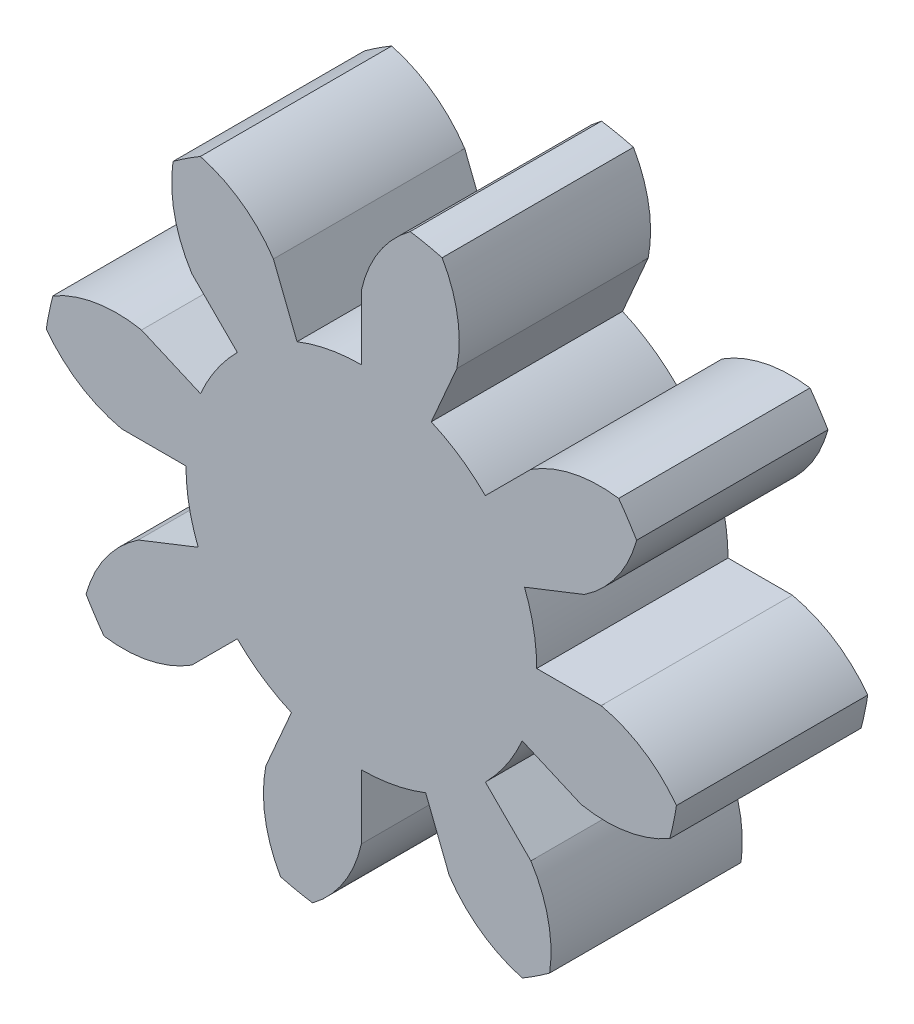
from build123d import *

# Parameters (mm, degrees)
BOSS_EXTRU_1_DEPTH           = 3
R_P_TITION_CIRCULAIRE2_COUNT = 8
ESQUISSE5_R                  = 2.75
BOSS_EXTRU_2_DEPTH           = 3


with BuildPart() as part:
    # Esquisse4 → Boss.-Extru.1 (new body)
    with BuildSketch(Plane.XY):
        with BuildLine():
            Line((0, 3.758770483), (0, 2.75))
            ThreePointArc((0, 2.75), (0.559711277, 2.692438168), (1.095991276, 2.52216239))
            Line((1.095991276, 2.52216239), (1.498028967, 3.447356198))
            ThreePointArc((1.498028967, 3.447356198), (1.508290586, 4.162952408), (1.26714265, 4.836770566))
            ThreePointArc((1.26714265, 4.836770566), (1.017656867, 4.895342123), (0.765497749, 4.941053855))
            ThreePointArc((0.765497749, 4.941053855), (0.275783903, 4.419169208), (0, 3.758770483))
        make_face()
    extrude(amount=BOSS_EXTRU_1_DEPTH)


with BuildPart() as r_p_tition_circulaire2_1:
    # Répétition circulaire2: pattern copy
    add(part.part.rotate(Axis((0, 0, 0), (0, 0, 1)), 1 * 360 / R_P_TITION_CIRCULAIRE2_COUNT))


with BuildPart() as r_p_tition_circulaire2_2:
    # Répétition circulaire2: pattern copy
    add(part.part.rotate(Axis((0, 0, 0), (0, 0, 1)), 2 * 360 / R_P_TITION_CIRCULAIRE2_COUNT))


with BuildPart() as r_p_tition_circulaire2_3:
    # Répétition circulaire2: pattern copy
    add(part.part.rotate(Axis((0, 0, 0), (0, 0, 1)), 3 * 360 / R_P_TITION_CIRCULAIRE2_COUNT))


with BuildPart() as r_p_tition_circulaire2_4:
    # Répétition circulaire2: pattern copy
    add(part.part.rotate(Axis((0, 0, 0), (0, 0, 1)), 4 * 360 / R_P_TITION_CIRCULAIRE2_COUNT))


with BuildPart() as r_p_tition_circulaire2_5:
    # Répétition circulaire2: pattern copy
    add(part.part.rotate(Axis((0, 0, 0), (0, 0, 1)), 5 * 360 / R_P_TITION_CIRCULAIRE2_COUNT))


with BuildPart() as r_p_tition_circulaire2_6:
    # Répétition circulaire2: pattern copy
    add(part.part.rotate(Axis((0, 0, 0), (0, 0, 1)), 6 * 360 / R_P_TITION_CIRCULAIRE2_COUNT))


with BuildPart() as r_p_tition_circulaire2_7:
    # Répétition circulaire2: pattern copy
    add(part.part.rotate(Axis((0, 0, 0), (0, 0, 1)), 7 * 360 / R_P_TITION_CIRCULAIRE2_COUNT))


with BuildPart() as part_1:
    add(part.part)

    add(r_p_tition_circulaire2_1.part)  # Boss.-Extru.2 merges Répétition circulaire2_1

    add(r_p_tition_circulaire2_2.part)  # Boss.-Extru.2 merges Répétition circulaire2_2

    add(r_p_tition_circulaire2_3.part)  # Boss.-Extru.2 merges Répétition circulaire2_3

    add(r_p_tition_circulaire2_4.part)  # Boss.-Extru.2 merges Répétition circulaire2_4

    add(r_p_tition_circulaire2_5.part)  # Boss.-Extru.2 merges Répétition circulaire2_5

    add(r_p_tition_circulaire2_6.part)  # Boss.-Extru.2 merges Répétition circulaire2_6

    add(r_p_tition_circulaire2_7.part)  # Boss.-Extru.2 merges Répétition circulaire2_7
    # Esquisse5 → Boss.-Extru.2 (add)
    with BuildSketch(Plane.XY):
        Circle(ESQUISSE5_R)
    extrude(amount=BOSS_EXTRU_2_DEPTH)


solid = part_1.part
